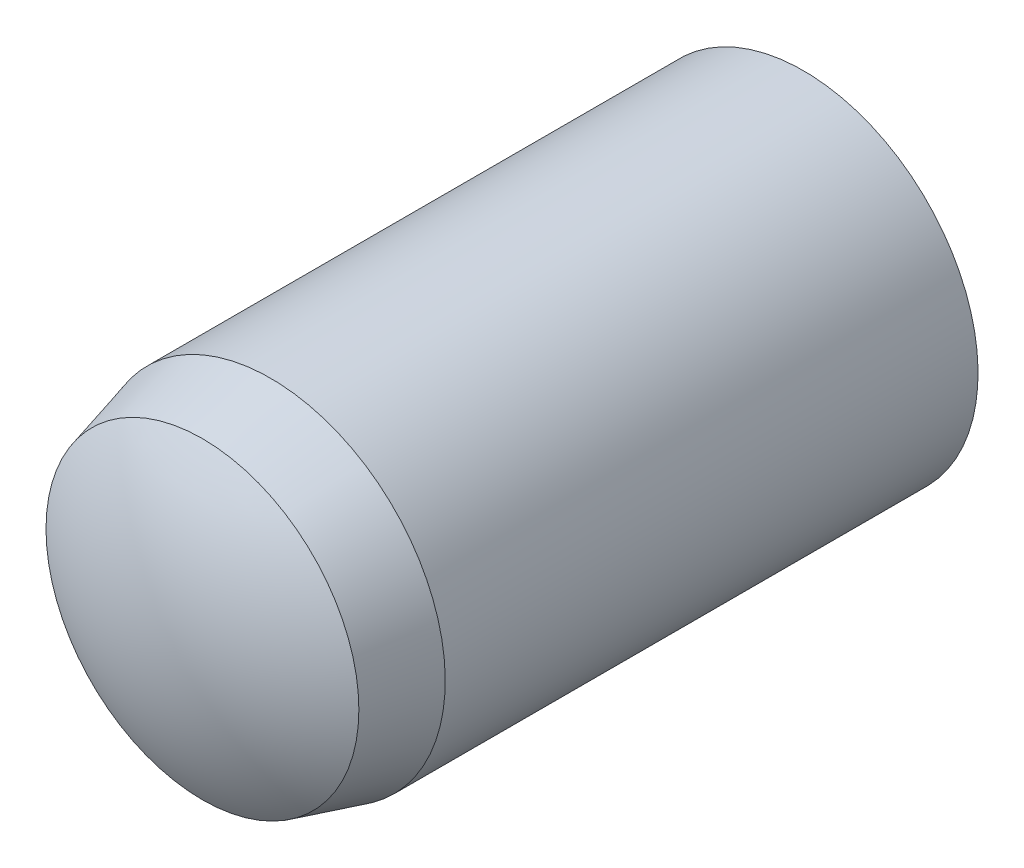
from build123d import *


with BuildPart() as part:
    # Sketch3 → Revolve1 (revolve)
    with BuildSketch(Plane(origin=(0, 0, 0), x_dir=(0, 0, -1), z_dir=(1, 0, 0))):
        with BuildLine():
            Line((-10, 0), (10, 0))
            ThreePointArc((10, 0), (9.616922091, 2.610076627), (8.5, 5))
            Line((8.5, 5), (-6.75, 5))
            Line((-6.75, 5), (-8.7, 4.477499075))
            ThreePointArc((-8.7, 4.477499075), (-9.668425132, 2.331201298), (-10, 0))
        make_face()
    revolve(axis=Axis((0, 0, 10), (0, 0, -1)))


solid = part.part
